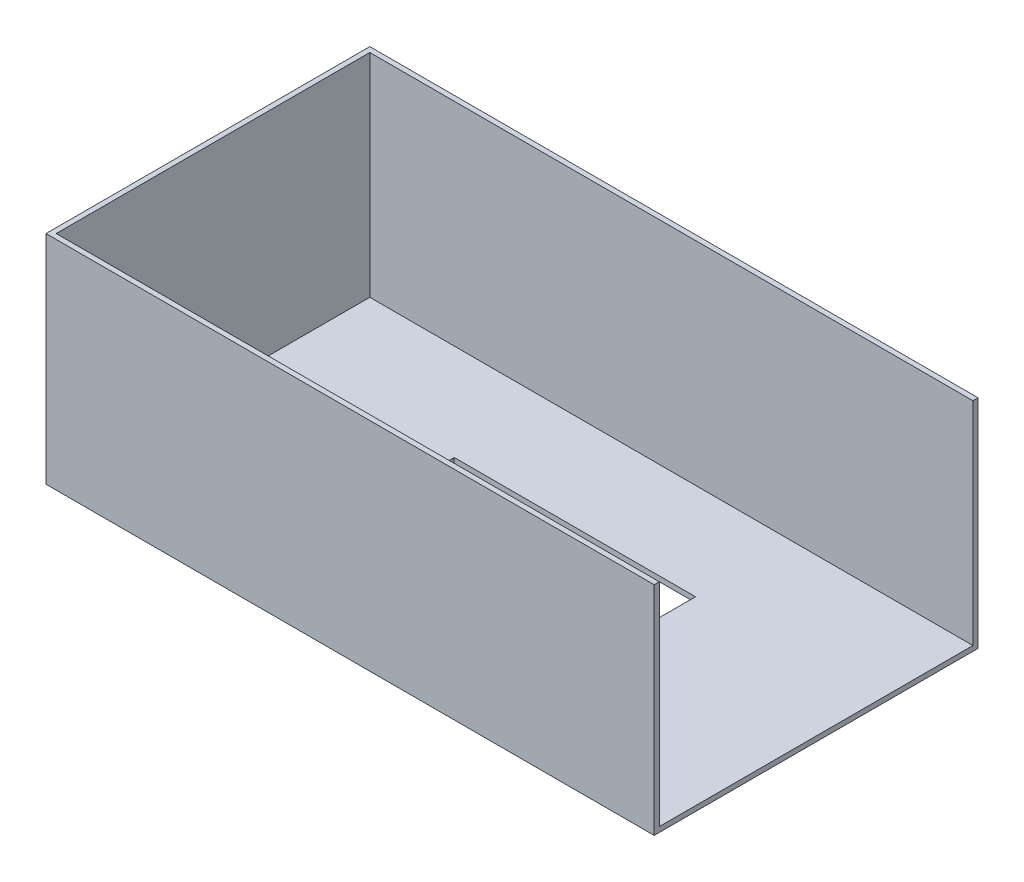
from build123d import *

# Parameters (mm, degrees)
CROQUIS1_W              = 250
CROQUIS1_H              = 130
SALIENTE_EXTRUIR1_DEPTH = 1.0555
CROQUIS3_W              = 250
CROQUIS3_H              = 90
SALIENTE_EXTRUIR2_DEPTH = 2.11
CROQUIS4_W              = 100
CROQUIS4_H              = 50
CORTAR_EXTRUIR1_DEPTH   = 2.111
CROQUIS5_W              = 134.22
CROQUIS5_H              = 90
SALIENTE_EXTRUIR3_DEPTH = 2.11


with BuildPart() as part:
    # Croquis1 → Saliente-Extruir1 (new body, symmetric)
    with BuildSketch(Plane(origin=(0, 0, 0), x_dir=(1, 0, 0), z_dir=(0, 1, 0))):
        Rectangle(CROQUIS1_W, CROQUIS1_H)
    extrude(amount=SALIENTE_EXTRUIR1_DEPTH, both=True)

    # Croquis3 → Saliente-Extruir2 (add)
    with BuildSketch(Plane.XY.offset(65)):
        with Locations((0, 43.9445)):
            Rectangle(CROQUIS3_W, CROQUIS3_H)
    saliente_extruir2 = extrude(amount=SALIENTE_EXTRUIR2_DEPTH)

    # Simetría1: Saliente-Extruir2 across plane
    add(saliente_extruir2.mirror(Plane.XY))

    # Croquis4 → Cortar-Extruir1 (cut)
    with BuildSketch(Plane(origin=(0, 1.0555, 0), x_dir=(1, 0, 0), z_dir=(0, 1, 0))):
        Rectangle(CROQUIS4_W, CROQUIS4_H)
    extrude(amount=-CORTAR_EXTRUIR1_DEPTH, mode=Mode.SUBTRACT)

    # Croquis5 → Saliente-Extruir3 (add)
    with BuildSketch(Plane.ZY.offset(125)):
        with Locations((0, 43.9445)):
            Rectangle(CROQUIS5_W, CROQUIS5_H)
    extrude(amount=SALIENTE_EXTRUIR3_DEPTH)


solid = part.part
